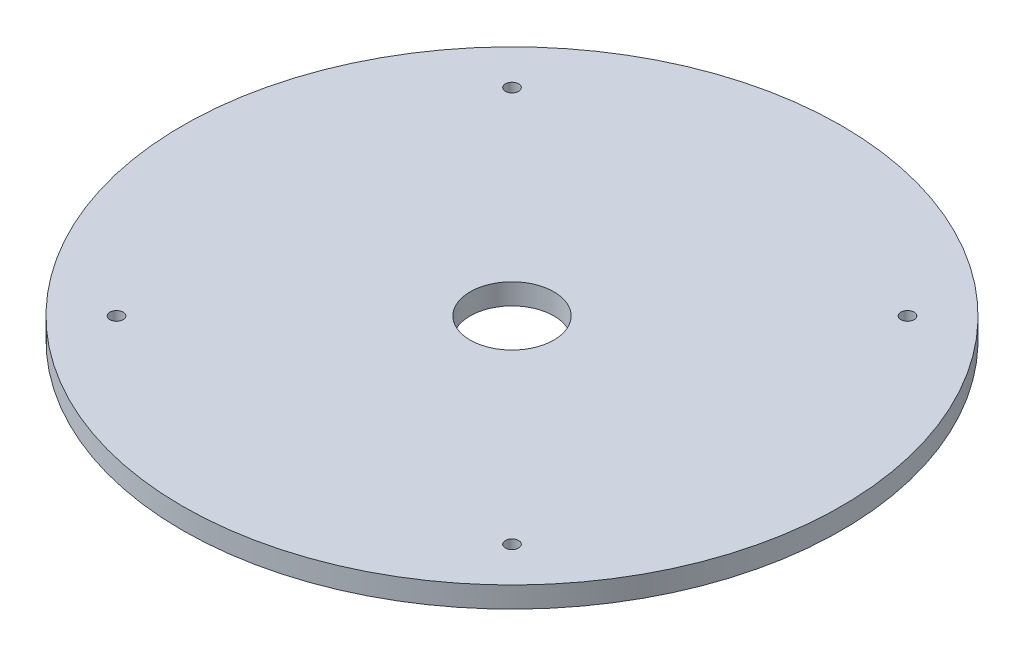
from build123d import *

# Parameters (mm, degrees)
SKETCH1_R           = 50
SKETCH1_R_2         = 1
SKETCH1_R_3         = 6.35
BOSS_EXTRUDE1_DEPTH = 3.175


with BuildPart() as part:
    # Sketch1 → Boss-Extrude1 (new body)
    with BuildSketch(Plane(origin=(0, 0, 0), x_dir=(1, 0, 0), z_dir=(0, 1, 0))):
        Circle(SKETCH1_R)
        with Locations((-30, 30)):
            Circle(SKETCH1_R_2, mode=Mode.SUBTRACT)
        with Locations((30, 30)):
            Circle(SKETCH1_R_2, mode=Mode.SUBTRACT)
        with Locations((30, -30)):
            Circle(SKETCH1_R_2, mode=Mode.SUBTRACT)
        with Locations((-30, -30)):
            Circle(SKETCH1_R_2, mode=Mode.SUBTRACT)
        Circle(SKETCH1_R_3, mode=Mode.SUBTRACT)
    extrude(amount=BOSS_EXTRUDE1_DEPTH)


solid = part.part
